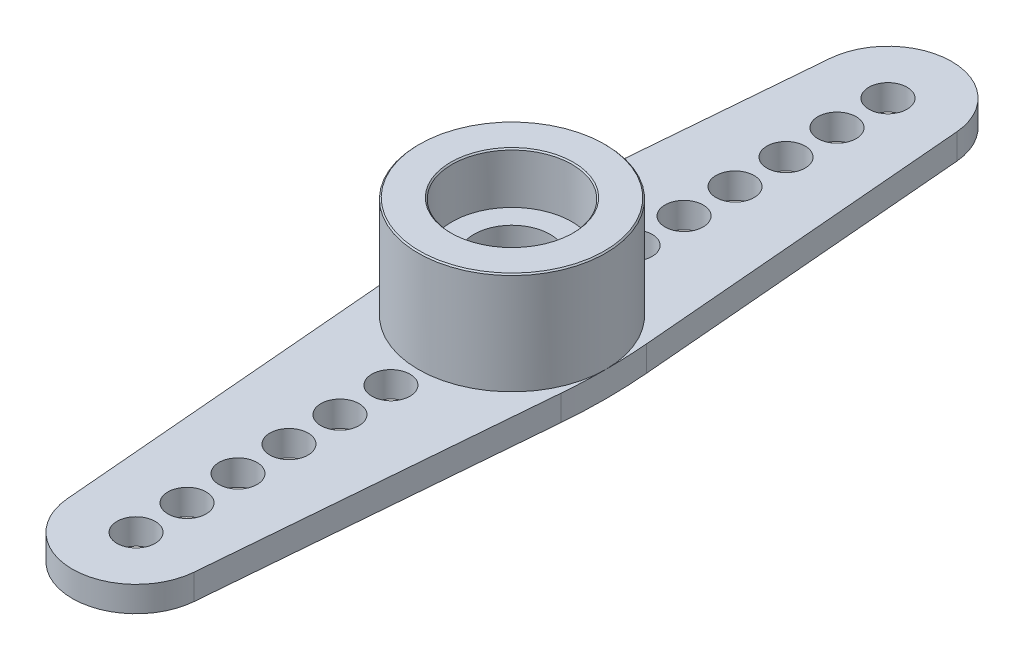
from build123d import *

# Parameters (mm, degrees)
SKETCH1_R           = 0.75
BOSS_EXTRUDE2_DEPTH = 1
SKETCH2_R           = 3.67931812
SKETCH2_R_2         = 1.5
BOSS_EXTRUDE6_DEPTH = 5
SKETCH4_R           = 0.75
BOSS_EXTRUDE7_DEPTH = 1
SKETCH5_R           = 1.5
CUT_EXTRUDE2_DEPTH  = 0.5
SKETCH1_5_R         = 0.75
CUT_EXTRUDE3_DEPTH  = 6
SKETCH6_R           = 2.355
CUT_EXTRUDE4_DEPTH  = 2
CHAMFER1_SIZE       = 0.05


with BuildPart() as part:
    # Sketch1 → Boss-Extrude2 (new body)
    with BuildSketch(Plane(origin=(0, 0, 0), x_dir=(1, 0, 0), z_dir=(0, 1, 0))):
        with BuildLine():
            ThreePointArc((2.49119588, 14.959626071), (0, 17.25), (-2.49119588, 14.959626071))
            Line((-2.49119588, 14.959626071), (-3.608885156, 1.677008569))
            ThreePointArc((-3.608885156, 1.677008569), (-3.67931812, 0), (-3.608885156, -1.677008569))
            Line((-3.608885156, -1.677008569), (-2.49119588, -14.959626071))
            ThreePointArc((-2.49119588, -14.959626071), (0, -17.25), (2.49119588, -14.959626071))
            Line((2.49119588, -14.959626071), (3.608885156, -1.677008569))
            ThreePointArc((3.608885156, -1.677008569), (3.67931812, 0), (3.608885156, 1.677008569))
            Line((3.608885156, 1.677008569), (2.49119588, 14.959626071))
        make_face()
        with Locations((0, -14.75)):
            Circle(SKETCH1_R, mode=Mode.SUBTRACT)
        with Locations((0, -12.75)):
            Circle(SKETCH1_R, mode=Mode.SUBTRACT)
        with Locations((0, -10.75)):
            Circle(SKETCH1_R, mode=Mode.SUBTRACT)
        with Locations((0, -8.75)):
            Circle(SKETCH1_R, mode=Mode.SUBTRACT)
        with Locations((0, -6.75)):
            Circle(SKETCH1_R, mode=Mode.SUBTRACT)
        with Locations((0, -4.75)):
            Circle(SKETCH1_R, mode=Mode.SUBTRACT)
        Circle(SKETCH1_R, mode=Mode.SUBTRACT)
        with Locations((0, 4.75)):
            Circle(SKETCH1_R, mode=Mode.SUBTRACT)
        with Locations((0, 6.75)):
            Circle(SKETCH1_R, mode=Mode.SUBTRACT)
        with Locations((0, 8.75)):
            Circle(SKETCH1_R, mode=Mode.SUBTRACT)
        with Locations((0, 10.75)):
            Circle(SKETCH1_R, mode=Mode.SUBTRACT)
        with Locations((0, 12.75)):
            Circle(SKETCH1_R, mode=Mode.SUBTRACT)
        with Locations((0, 14.75)):
            Circle(SKETCH1_R, mode=Mode.SUBTRACT)
    extrude(amount=BOSS_EXTRUDE2_DEPTH)

    # Sketch2 → Boss-Extrude6 (add)
    with BuildSketch(Plane.XZ):
        Circle(SKETCH2_R)
        Circle(SKETCH2_R_2, mode=Mode.SUBTRACT)
    extrude(amount=-BOSS_EXTRUDE6_DEPTH)

    # Sketch4 → Boss-Extrude7 (add)
    with BuildSketch(Plane.XZ):
        Circle(SKETCH4_R)
    extrude(amount=-BOSS_EXTRUDE7_DEPTH)

    # Sketch5 → Cut-Extrude2 (cut)
    with BuildSketch(Plane.XZ):
        Circle(SKETCH5_R)
    extrude(amount=-CUT_EXTRUDE2_DEPTH, mode=Mode.SUBTRACT)

    # Sketch1_5 → Cut-Extrude3 (cut, through all)
    with BuildSketch(Plane(origin=(0, 0, 0), x_dir=(1, 0, 0), z_dir=(0, 1, 0))):
        Circle(SKETCH1_5_R)
    extrude(amount=CUT_EXTRUDE3_DEPTH, mode=Mode.SUBTRACT)

    # Sketch6 → Cut-Extrude4 (cut)
    with BuildSketch(Plane(origin=(0, 5, 0), x_dir=(1, 0, 0), z_dir=(0, 1, 0))):
        Circle(SKETCH6_R)
    extrude(amount=-CUT_EXTRUDE4_DEPTH, mode=Mode.SUBTRACT)

    # Chamfer1
    chamfer1_edges = [part.edges().sort_by_distance(p)[0] for p in [
        (-3.67931812, 5, 0),
        (-2.355, 5, 0),
    ]]
    chamfer(chamfer1_edges, length=CHAMFER1_SIZE)


solid = part.part
